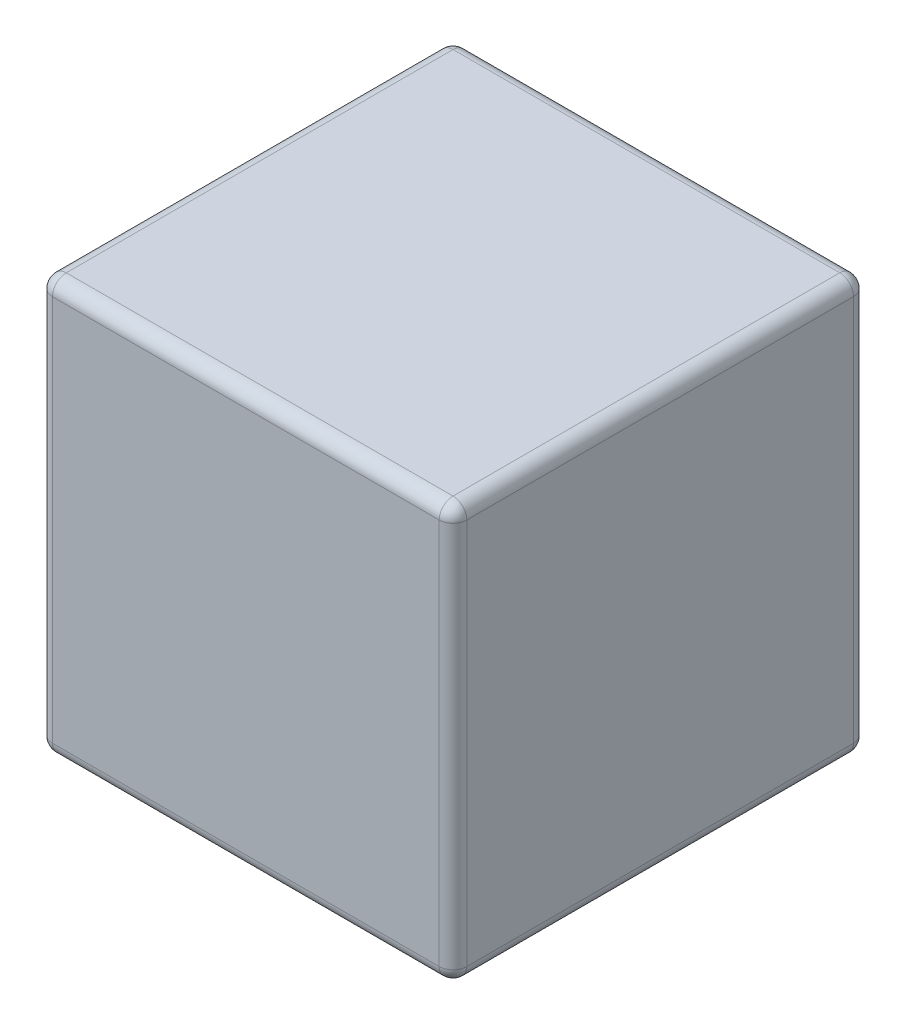
from build123d import *

# Parameters (mm, degrees)
SKETCH1_W           = 3
SKETCH1_H           = 3
BOSS_EXTRUDE1_DEPTH = 1.5
FILLET1_R           = 0.1


with BuildPart() as part:
    # Sketch1 → Boss-Extrude1 (new body, symmetric)
    with BuildSketch(Plane.YZ):
        with Locations((1.5, 1.5)):
            Rectangle(SKETCH1_W, SKETCH1_H)
    extrude(amount=BOSS_EXTRUDE1_DEPTH, both=True)

    # Fillet1
    fillet1_edges = [part.edges().sort_by_distance(p)[0] for p in [
        (1.5, 3, 1.5),
        (1.5, 1.5, 3),
        (1.5, 0, 1.5),
        (-1.5, 1.5, 3),
        (-1.5, 3, 1.5),
        (-1.5, 1.5, 0),
        (-1.5, 0, 1.5),
        (0, 0, 3),
        (0, 3, 3),
        (0, 3, 0),
        (0, 0, 0),
        (1.5, 1.5, 0),
    ]]
    fillet(fillet1_edges, radius=FILLET1_R)


solid = part.part
